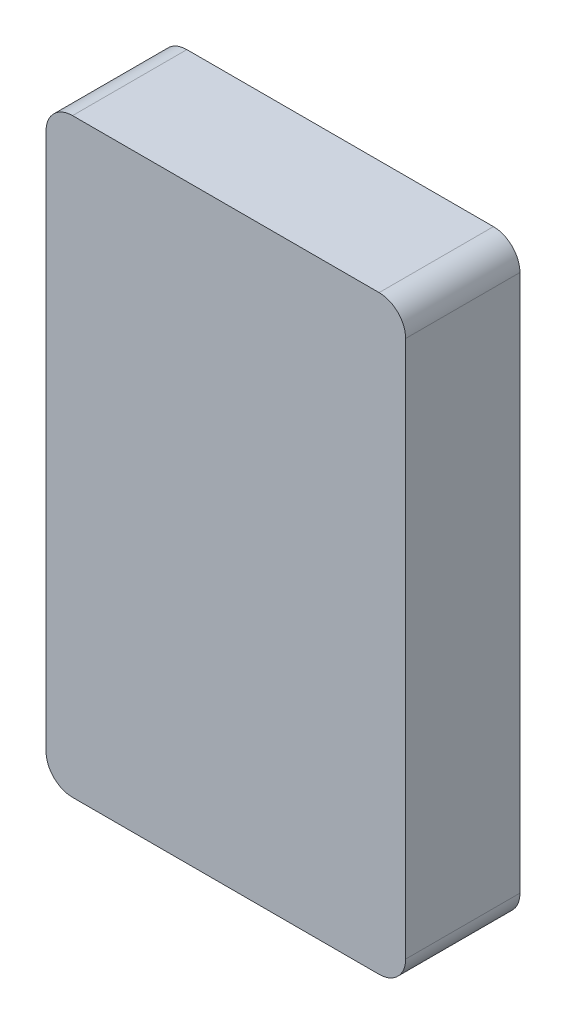
from build123d import *

# Parameters (mm, degrees)
SKETCH1_W           = 395
SKETCH1_H           = 700
BOSS_EXTRUDE1_DEPTH = 150
BOSS_EXTRUDE2_DEPTH = 1


with BuildPart() as part:
    # Sketch1 → Boss-Extrude1 (new body)
    with BuildSketch(Plane.XY):
        with BuildLine():
            Line((-400, 740), (5, 740))
            ThreePointArc((5, 740), (29.748737342, 729.748737342), (40, 705))
            Line((40, 705), (40, -5))
            ThreePointArc((40, -5), (29.748737342, -29.748737342), (5, -40))
            Line((5, -40), (-400, -40))
            ThreePointArc((-400, -40), (-424.748737342, -29.748737342), (-435, -5))
            Line((-435, -5), (-435, 705))
            ThreePointArc((-435, 705), (-424.748737342, 729.748737342), (-400, 740))
        make_face()
        with Locations((-197.5, 350)):
            Rectangle(SKETCH1_W, SKETCH1_H, mode=Mode.SUBTRACT)
    extrude(amount=BOSS_EXTRUDE1_DEPTH)

    # Sketch2 → Boss-Extrude2 (add)
    with BuildSketch(Plane.XY.offset(150)):
        with BuildLine():
            Line((-400, -40), (5, -40))
            ThreePointArc((5, -40), (29.748737342, -29.748737342), (40, -5))
            Line((40, -5), (40, 705))
            ThreePointArc((40, 705), (29.748737342, 729.748737342), (5, 740))
            Line((5, 740), (-400, 740))
            ThreePointArc((-400, 740), (-424.748737342, 729.748737342), (-435, 705))
            Line((-435, 705), (-435, -5))
            ThreePointArc((-435, -5), (-424.748737342, -29.748737342), (-400, -40))
        make_face()
    extrude(amount=BOSS_EXTRUDE2_DEPTH)


solid = part.part
